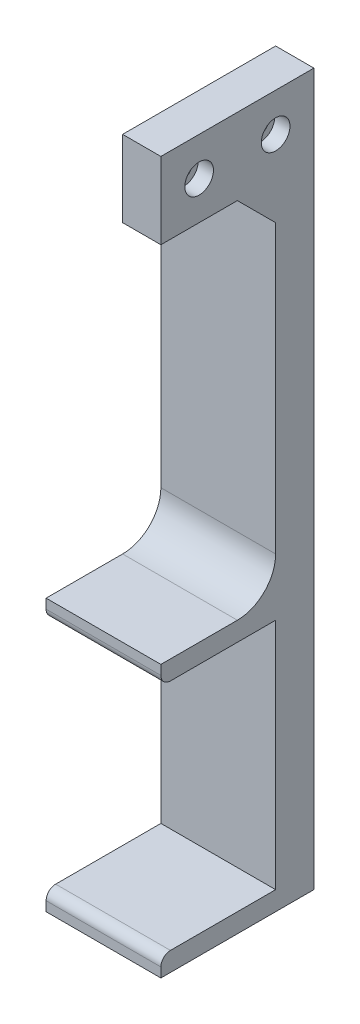
from build123d import *

# Parameters (mm, degrees)
SKETCH_1_W          = 30
SKETCH_1_H          = 186
EXTRUDE_1_DEPTH     = 10
SKETCH_2_W          = 30
SKETCH_2_H          = 5
SKETCH_2_H_2        = 20
EXTRUDE_2_DEPTH     = 30
FILLET_1_R          = 2.5
FILLET_4_R          = 10
CHAMFER_7_SIZE      = 10
SKETCH_3_W          = 40
SKETCH_3_H          = 20
CUT_EXTRUDE_1_DEPTH = 20
SKETCH_7_R          = 2.05
CUT_EXTRUDE_3_DEPTH = 10
SKETCH_8_R          = 3.75
CUT_EXTRUDE_4_DEPTH = 4


with BuildPart() as part:
    # 草圖1 → 填料-伸長1 (new body)
    with BuildSketch(Plane.XY):
        with Locations((3.2037008, 67.330357143)):
            Rectangle(SKETCH_1_W, SKETCH_1_H)
    extrude(amount=EXTRUDE_1_DEPTH)

    # 草圖2 → 填料-伸長2 (add)
    with BuildSketch(Plane.XY.offset(10)):
        with Locations((3.2037008, -23.169642857)):
            Rectangle(SKETCH_2_W, SKETCH_2_H)
        with Locations((3.2037008, 42.830357143)):
            Rectangle(SKETCH_2_W, SKETCH_2_H)
        with Locations((3.2037008, 150.330357143)):
            Rectangle(SKETCH_2_W, SKETCH_2_H_2)
    extrude(amount=EXTRUDE_2_DEPTH)

    # 圓角1
    fillet_1_edges = [part.edges().sort_by_distance(p)[0] for p in [
        (3.2037008, -20.669642857, 40),
        (3.2037008, 40.330357143, 40),
    ]]
    fillet(fillet_1_edges, radius=FILLET_1_R)

    # 圓角4
    fillet_4_edges = [part.edges().sort_by_distance(p)[0] for p in [
        (3.2037008, 45.330357143, 10),
    ]]
    fillet(fillet_4_edges, radius=FILLET_4_R)

    # 導角7
    chamfer_7_edges = [part.edges().sort_by_distance(p)[0] for p in [
        (3.2037008, 140.330357143, 10),
    ]]
    chamfer(chamfer_7_edges, length=CHAMFER_7_SIZE)

    # 草圖3 → 除料-伸長1 (cut)
    with BuildSketch(Plane.ZY.offset(11.7962992)):
        with Locations((20, 150.330357143)):
            Rectangle(SKETCH_3_W, SKETCH_3_H)
    extrude(amount=-CUT_EXTRUDE_1_DEPTH, mode=Mode.SUBTRACT)

    # 草圖7 → 除料-伸長3 (cut)
    with BuildSketch(Plane.ZY.offset(-8.2037008)):
        with Locations((30, 150.330357143)):
            Circle(SKETCH_7_R)
        with Locations((10, 150.330357143)):
            Circle(SKETCH_7_R)
    extrude(amount=-CUT_EXTRUDE_3_DEPTH, mode=Mode.SUBTRACT)

    # 草圖8 → 除料-伸長4 (cut)
    with BuildSketch(Plane(origin=(18.2037008, 0, 0), x_dir=(0, 0, -1), z_dir=(1, 0, 0))):
        with Locations((-30, 150.330357143)):
            Circle(SKETCH_8_R)
        with Locations((-10, 150.330357143)):
            Circle(SKETCH_8_R)
    extrude(amount=-CUT_EXTRUDE_4_DEPTH, mode=Mode.SUBTRACT)


solid = part.part
